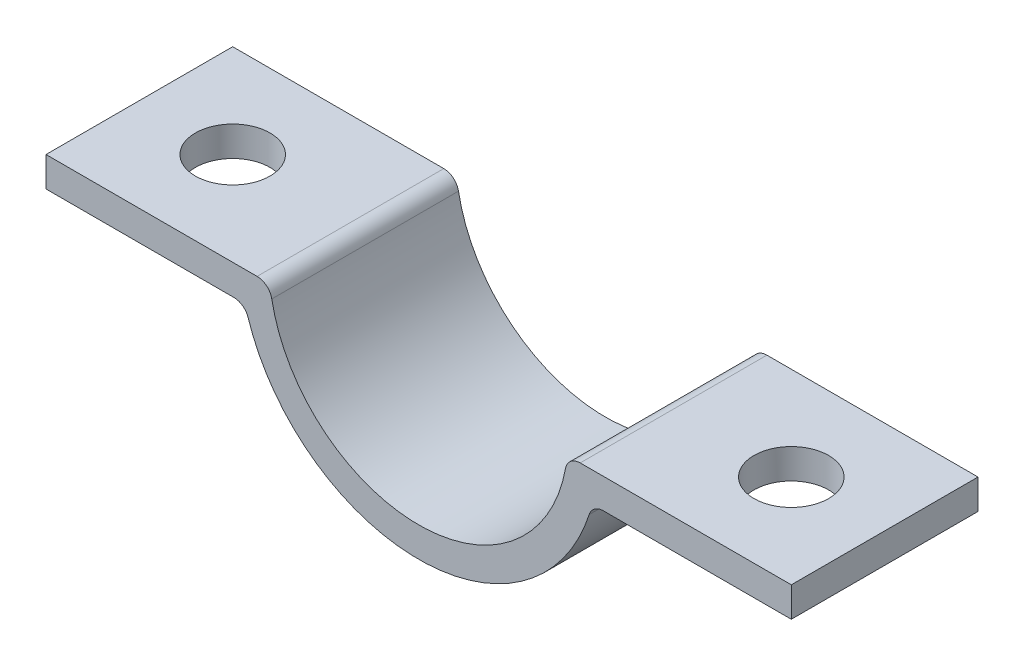
from build123d import *

# Parameters (mm, degrees)
BOSS_EXTRUDE2_DEPTH = 12.5
CUT_EXTRUDE1_REACH  = 13
SKETCH4_R           = 2.5


with BuildPart() as part:
    # Sketch3 → Boss-Extrude2 (new body)
    with BuildSketch(Plane.XY):
        with BuildLine():
            Line((-10.816653826, 19.01731952), (-19.949874371, 19.01731952))
            Line((-19.949874371, 19.01731952), (-24.949874371, 19.01731952))
            Line((-24.949874371, 19.01731952), (-24.949874371, 17.01731952))
            Line((-24.949874371, 17.01731952), (-19.949874371, 17.01731952))
            Line((-19.949874371, 17.01731952), (-12.369316877, 17.01731952))
            ThreePointArc((-12.369316877, 17.01731952), (-11.780968471, 16.82592706), (-11.417830963, 16.325011828))
            ThreePointArc((-11.417830963, 16.325011828), (0, 8.01731952), (11.417830963, 16.325011828))
            ThreePointArc((11.417830963, 16.325011828), (11.780968471, 16.82592706), (12.369316877, 17.01731952))
            Line((12.369316877, 17.01731952), (19.949874371, 17.01731952))
            Line((19.949874371, 17.01731952), (24.949874371, 17.01731952))
            Line((24.949874371, 17.01731952), (24.949874371, 19.01731952))
            Line((24.949874371, 19.01731952), (19.949874371, 19.01731952))
            Line((19.949874371, 19.01731952), (10.816653826, 19.01731952))
            ThreePointArc((10.816653826, 19.01731952), (10.177051677, 18.786025635), (9.83332166, 18.199137702))
            ThreePointArc((9.83332166, 18.199137702), (0, 10.01731952), (-9.83332166, 18.199137702))
            ThreePointArc((-9.83332166, 18.199137702), (-10.177051677, 18.786025635), (-10.816653826, 19.01731952))
        make_face()
    extrude(amount=BOSS_EXTRUDE2_DEPTH)

    # Sketch4 → Cut-Extrude1 (cut, up to next)
    with BuildSketch(Plane(origin=(0, 19.01731952, 0), x_dir=(1, 0, 0), z_dir=(0, 1, 0)), mode=Mode.PRIVATE) as cut_extrude1_sk1:
        with Locations((-18.699874371, -6.25)):
            Circle(SKETCH4_R)
    cut_extrude1_tool1 = extrude(cut_extrude1_sk1.sketch, amount=-CUT_EXTRUDE1_REACH, mode=Mode.PRIVATE) & part.part
    add(cut_extrude1_tool1.solids().sort_by_distance((-18.699874, 19.01732, 6.25))[0], mode=Mode.SUBTRACT)
    # Sketch4 → Cut-Extrude1 (cut, up to next)
    with BuildSketch(Plane(origin=(0, 19.01731952, 0), x_dir=(1, 0, 0), z_dir=(0, 1, 0)), mode=Mode.PRIVATE) as cut_extrude1_sk2:
        with Locations((18.699874371, -6.25)):
            Circle(SKETCH4_R)
    cut_extrude1_tool2 = extrude(cut_extrude1_sk2.sketch, amount=-CUT_EXTRUDE1_REACH, mode=Mode.PRIVATE) & part.part
    add(cut_extrude1_tool2.solids().sort_by_distance((18.699874, 19.01732, 6.25))[0], mode=Mode.SUBTRACT)


solid = part.part
